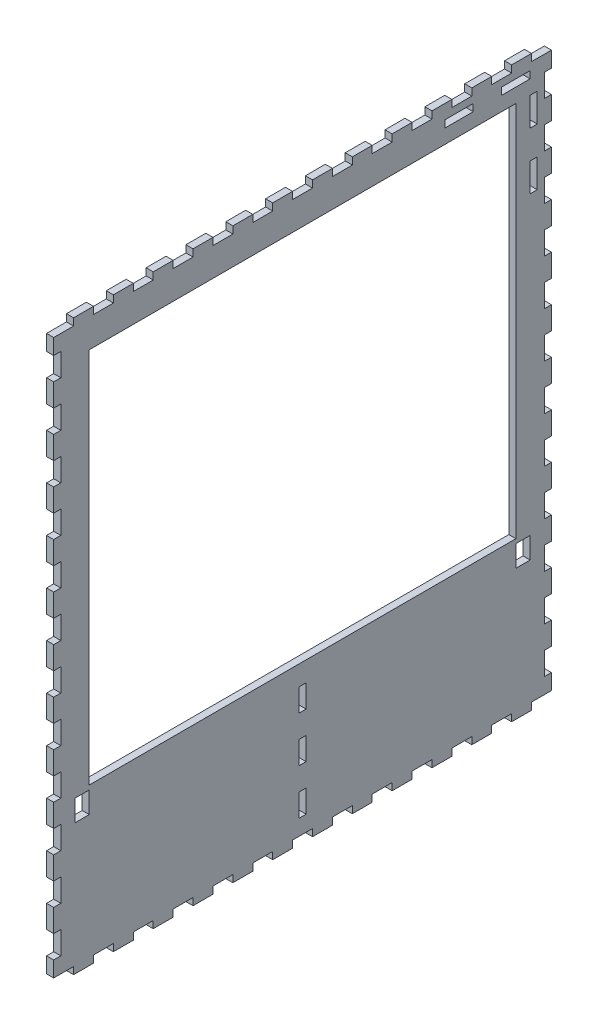
from build123d import *

# Parameters (mm, degrees)
ESQUISSE1_W                = 350
ESQUISSE1_H                = 400
BOSS_EXTRU_1_DEPTH         = 5
ESQUISSE2_W                = 14
ESQUISSE2_H                = 5
ENL_V_MAT_EXTRU_1_DEPTH    = 5
R_P_TITION_LIN_AIRE1_COUNT = 13
R_P_TITION_LIN_AIRE1_PITCH = 28
SYM_TRIE1_COPY_1_SKETCH_W  = 14
SYM_TRIE1_COPY_1_SKETCH_H  = 5
SYM_TRIE1_COPY_1_DEPTH     = 5
SYM_TRIE1_COPY_2_SKETCH_W  = 14
SYM_TRIE1_COPY_2_SKETCH_H  = 5
SYM_TRIE1_COPY_2_DEPTH     = 5
SYM_TRIE1_COPY_3_SKETCH_W  = 14
SYM_TRIE1_COPY_3_SKETCH_H  = 5
SYM_TRIE1_COPY_3_DEPTH     = 5
SYM_TRIE1_COPY_4_SKETCH_W  = 14
SYM_TRIE1_COPY_4_SKETCH_H  = 5
SYM_TRIE1_COPY_4_DEPTH     = 5
SYM_TRIE1_COPY_5_SKETCH_W  = 14
SYM_TRIE1_COPY_5_SKETCH_H  = 5
SYM_TRIE1_COPY_5_DEPTH     = 5
SYM_TRIE1_COPY_6_SKETCH_W  = 14
SYM_TRIE1_COPY_6_SKETCH_H  = 5
SYM_TRIE1_COPY_6_DEPTH     = 5
SYM_TRIE1_COPY_7_SKETCH_W  = 14
SYM_TRIE1_COPY_7_SKETCH_H  = 5
SYM_TRIE1_COPY_7_DEPTH     = 5
SYM_TRIE1_COPY_8_SKETCH_W  = 14
SYM_TRIE1_COPY_8_SKETCH_H  = 5
SYM_TRIE1_COPY_8_DEPTH     = 5
SYM_TRIE1_COPY_9_SKETCH_W  = 14
SYM_TRIE1_COPY_9_SKETCH_H  = 5
SYM_TRIE1_COPY_9_DEPTH     = 5
SYM_TRIE1_COPY_10_SKETCH_W = 14
SYM_TRIE1_COPY_10_SKETCH_H = 5
SYM_TRIE1_COPY_10_DEPTH    = 5
SYM_TRIE1_COPY_11_SKETCH_W = 14
SYM_TRIE1_COPY_11_SKETCH_H = 5
SYM_TRIE1_COPY_11_DEPTH    = 5
SYM_TRIE1_COPY_12_SKETCH_W = 14
SYM_TRIE1_COPY_12_SKETCH_H = 5
SYM_TRIE1_COPY_12_DEPTH    = 5
ESQUISSE3_W                = 5
ESQUISSE3_H                = 16
ENL_V_MAT_EXTRU_2_DEPTH    = 5
R_P_TITION_LIN_AIRE2_COUNT = 12
R_P_TITION_LIN_AIRE2_PITCH = 32
SYM_TRIE2_COPY_1_SKETCH_W  = 5
SYM_TRIE2_COPY_1_SKETCH_H  = 16
SYM_TRIE2_COPY_1_DEPTH     = 5
SYM_TRIE2_COPY_2_SKETCH_W  = 5
SYM_TRIE2_COPY_2_SKETCH_H  = 16
SYM_TRIE2_COPY_2_DEPTH     = 5
SYM_TRIE2_COPY_3_SKETCH_W  = 5
SYM_TRIE2_COPY_3_SKETCH_H  = 16
SYM_TRIE2_COPY_3_DEPTH     = 5
SYM_TRIE2_COPY_4_SKETCH_W  = 5
SYM_TRIE2_COPY_4_SKETCH_H  = 16
SYM_TRIE2_COPY_4_DEPTH     = 5
SYM_TRIE2_COPY_5_SKETCH_W  = 5
SYM_TRIE2_COPY_5_SKETCH_H  = 16
SYM_TRIE2_COPY_5_DEPTH     = 5
SYM_TRIE2_COPY_6_SKETCH_W  = 5
SYM_TRIE2_COPY_6_SKETCH_H  = 16
SYM_TRIE2_COPY_6_DEPTH     = 5
SYM_TRIE2_COPY_7_SKETCH_W  = 5
SYM_TRIE2_COPY_7_SKETCH_H  = 16
SYM_TRIE2_COPY_7_DEPTH     = 5
SYM_TRIE2_COPY_8_SKETCH_W  = 5
SYM_TRIE2_COPY_8_SKETCH_H  = 16
SYM_TRIE2_COPY_8_DEPTH     = 5
SYM_TRIE2_COPY_9_SKETCH_W  = 5
SYM_TRIE2_COPY_9_SKETCH_H  = 16
SYM_TRIE2_COPY_9_DEPTH     = 5
SYM_TRIE2_COPY_10_SKETCH_W = 5
SYM_TRIE2_COPY_10_SKETCH_H = 16
SYM_TRIE2_COPY_10_DEPTH    = 5
SYM_TRIE2_COPY_11_SKETCH_W = 5
SYM_TRIE2_COPY_11_SKETCH_H = 16
SYM_TRIE2_COPY_11_DEPTH    = 5
ESQUISSE4_W                = 300
ESQUISSE4_H                = 265
ENL_V_MAT_EXTRU_3_DEPTH    = 5
ESQUISSE5_W                = 10
ESQUISSE5_H                = 15
ENL_V_MAT_EXTRU_4_DEPTH    = 5
ESQUISSE6_W                = 5
ESQUISSE6_H                = 16
ENL_V_MAT_EXTRU_5_DEPTH    = 5
R_P_TITION_LIN_AIRE3_COUNT = 3
R_P_TITION_LIN_AIRE3_PITCH = 32
ESQUISSE7_W                = 20
ESQUISSE7_H                = 5
ESQUISSE7_W_2              = 5
ESQUISSE7_H_2              = 20
ENL_V_MAT_EXTRU_6_DEPTH    = 10


with BuildPart() as part:
    # Esquisse1 → Boss.-Extru.1 (new body)
    with BuildSketch(Plane(origin=(0, 0, 0), x_dir=(0, 0, -1), z_dir=(1, 0, 0))):
        with Locations((175, -200)):
            Rectangle(ESQUISSE1_W, ESQUISSE1_H)
    extrude(amount=BOSS_EXTRU_1_DEPTH)

    # Esquisse2 → Enlèv. mat.-Extru.1 (cut)
    with BuildSketch(Plane(origin=(5, 0, 0), x_dir=(0, 0, -1), z_dir=(1, 0, 0))):
        with Locations((343, -397.5)):
            Rectangle(ESQUISSE2_W, ESQUISSE2_H)
    enl_v_mat_extru_1 = extrude(amount=-ENL_V_MAT_EXTRU_1_DEPTH, mode=Mode.SUBTRACT)

    # Répétition linéaire1: Enlèv. mat.-Extru.1 ×13
    with Locations(*[(0, 0, i * R_P_TITION_LIN_AIRE1_PITCH) for i in range(1, R_P_TITION_LIN_AIRE1_COUNT)]):
        add(enl_v_mat_extru_1, mode=Mode.SUBTRACT)

    # Symétrie1: Enlèv. mat.-Extru.1 across plane
    add(enl_v_mat_extru_1.mirror(Plane(origin=(0, -200, 0), x_dir=(0, 0, 1), z_dir=(0, -1, 0))), mode=Mode.SUBTRACT)

    # Symétrie1 copy 1 sketch → Symétrie1 copy 1 (cut)
    with BuildSketch(Plane(origin=(5, -400, 28), x_dir=(0, 0, -1), z_dir=(1, 0, 0))):
        with Locations((343, 397.5)):
            Rectangle(SYM_TRIE1_COPY_1_SKETCH_W, SYM_TRIE1_COPY_1_SKETCH_H)
    extrude(amount=-SYM_TRIE1_COPY_1_DEPTH, mode=Mode.SUBTRACT)

    # Symétrie1 copy 2 sketch → Symétrie1 copy 2 (cut)
    with BuildSketch(Plane(origin=(5, -400, 56), x_dir=(0, 0, -1), z_dir=(1, 0, 0))):
        with Locations((343, 397.5)):
            Rectangle(SYM_TRIE1_COPY_2_SKETCH_W, SYM_TRIE1_COPY_2_SKETCH_H)
    extrude(amount=-SYM_TRIE1_COPY_2_DEPTH, mode=Mode.SUBTRACT)

    # Symétrie1 copy 3 sketch → Symétrie1 copy 3 (cut)
    with BuildSketch(Plane(origin=(5, -400, 84), x_dir=(0, 0, -1), z_dir=(1, 0, 0))):
        with Locations((343, 397.5)):
            Rectangle(SYM_TRIE1_COPY_3_SKETCH_W, SYM_TRIE1_COPY_3_SKETCH_H)
    extrude(amount=-SYM_TRIE1_COPY_3_DEPTH, mode=Mode.SUBTRACT)

    # Symétrie1 copy 4 sketch → Symétrie1 copy 4 (cut)
    with BuildSketch(Plane(origin=(5, -400, 112), x_dir=(0, 0, -1), z_dir=(1, 0, 0))):
        with Locations((343, 397.5)):
            Rectangle(SYM_TRIE1_COPY_4_SKETCH_W, SYM_TRIE1_COPY_4_SKETCH_H)
    extrude(amount=-SYM_TRIE1_COPY_4_DEPTH, mode=Mode.SUBTRACT)

    # Symétrie1 copy 5 sketch → Symétrie1 copy 5 (cut)
    with BuildSketch(Plane(origin=(5, -400, 140), x_dir=(0, 0, -1), z_dir=(1, 0, 0))):
        with Locations((343, 397.5)):
            Rectangle(SYM_TRIE1_COPY_5_SKETCH_W, SYM_TRIE1_COPY_5_SKETCH_H)
    extrude(amount=-SYM_TRIE1_COPY_5_DEPTH, mode=Mode.SUBTRACT)

    # Symétrie1 copy 6 sketch → Symétrie1 copy 6 (cut)
    with BuildSketch(Plane(origin=(5, -400, 168), x_dir=(0, 0, -1), z_dir=(1, 0, 0))):
        with Locations((343, 397.5)):
            Rectangle(SYM_TRIE1_COPY_6_SKETCH_W, SYM_TRIE1_COPY_6_SKETCH_H)
    extrude(amount=-SYM_TRIE1_COPY_6_DEPTH, mode=Mode.SUBTRACT)

    # Symétrie1 copy 7 sketch → Symétrie1 copy 7 (cut)
    with BuildSketch(Plane(origin=(5, -400, 196), x_dir=(0, 0, -1), z_dir=(1, 0, 0))):
        with Locations((343, 397.5)):
            Rectangle(SYM_TRIE1_COPY_7_SKETCH_W, SYM_TRIE1_COPY_7_SKETCH_H)
    extrude(amount=-SYM_TRIE1_COPY_7_DEPTH, mode=Mode.SUBTRACT)

    # Symétrie1 copy 8 sketch → Symétrie1 copy 8 (cut)
    with BuildSketch(Plane(origin=(5, -400, 224), x_dir=(0, 0, -1), z_dir=(1, 0, 0))):
        with Locations((343, 397.5)):
            Rectangle(SYM_TRIE1_COPY_8_SKETCH_W, SYM_TRIE1_COPY_8_SKETCH_H)
    extrude(amount=-SYM_TRIE1_COPY_8_DEPTH, mode=Mode.SUBTRACT)

    # Symétrie1 copy 9 sketch → Symétrie1 copy 9 (cut)
    with BuildSketch(Plane(origin=(5, -400, 252), x_dir=(0, 0, -1), z_dir=(1, 0, 0))):
        with Locations((343, 397.5)):
            Rectangle(SYM_TRIE1_COPY_9_SKETCH_W, SYM_TRIE1_COPY_9_SKETCH_H)
    extrude(amount=-SYM_TRIE1_COPY_9_DEPTH, mode=Mode.SUBTRACT)

    # Symétrie1 copy 10 sketch → Symétrie1 copy 10 (cut)
    with BuildSketch(Plane(origin=(5, -400, 280), x_dir=(0, 0, -1), z_dir=(1, 0, 0))):
        with Locations((343, 397.5)):
            Rectangle(SYM_TRIE1_COPY_10_SKETCH_W, SYM_TRIE1_COPY_10_SKETCH_H)
    extrude(amount=-SYM_TRIE1_COPY_10_DEPTH, mode=Mode.SUBTRACT)

    # Symétrie1 copy 11 sketch → Symétrie1 copy 11 (cut)
    with BuildSketch(Plane(origin=(5, -400, 308), x_dir=(0, 0, -1), z_dir=(1, 0, 0))):
        with Locations((343, 397.5)):
            Rectangle(SYM_TRIE1_COPY_11_SKETCH_W, SYM_TRIE1_COPY_11_SKETCH_H)
    extrude(amount=-SYM_TRIE1_COPY_11_DEPTH, mode=Mode.SUBTRACT)

    # Symétrie1 copy 12 sketch → Symétrie1 copy 12 (cut)
    with BuildSketch(Plane(origin=(5, -400, 336), x_dir=(0, 0, -1), z_dir=(1, 0, 0))):
        with Locations((343, 397.5)):
            Rectangle(SYM_TRIE1_COPY_12_SKETCH_W, SYM_TRIE1_COPY_12_SKETCH_H)
    extrude(amount=-SYM_TRIE1_COPY_12_DEPTH, mode=Mode.SUBTRACT)

    # Esquisse3 → Enlèv. mat.-Extru.2 (cut)
    with BuildSketch(Plane(origin=(5, 0, 0), x_dir=(0, 0, -1), z_dir=(1, 0, 0))):
        with Locations((347.5, -376)):
            Rectangle(ESQUISSE3_W, ESQUISSE3_H)
    enl_v_mat_extru_2 = extrude(amount=-ENL_V_MAT_EXTRU_2_DEPTH, mode=Mode.SUBTRACT)

    # Répétition linéaire2: Enlèv. mat.-Extru.2 ×12
    with Locations(*[(0, i * R_P_TITION_LIN_AIRE2_PITCH, 0) for i in range(1, R_P_TITION_LIN_AIRE2_COUNT)]):
        add(enl_v_mat_extru_2, mode=Mode.SUBTRACT)

    # Symétrie2: Enlèv. mat.-Extru.2 across plane
    add(enl_v_mat_extru_2.mirror(Plane(origin=(0, 0, -175), x_dir=(1, 0, 0), z_dir=(0, 0, -1))), mode=Mode.SUBTRACT)

    # Symétrie2 copy 1 sketch → Symétrie2 copy 1 (cut)
    with BuildSketch(Plane(origin=(5, 32, -350), x_dir=(0, 0, 1), z_dir=(1, 0, 0))):
        with Locations((347.5, 376)):
            Rectangle(SYM_TRIE2_COPY_1_SKETCH_W, SYM_TRIE2_COPY_1_SKETCH_H)
    extrude(amount=-SYM_TRIE2_COPY_1_DEPTH, mode=Mode.SUBTRACT)

    # Symétrie2 copy 2 sketch → Symétrie2 copy 2 (cut)
    with BuildSketch(Plane(origin=(5, 64, -350), x_dir=(0, 0, 1), z_dir=(1, 0, 0))):
        with Locations((347.5, 376)):
            Rectangle(SYM_TRIE2_COPY_2_SKETCH_W, SYM_TRIE2_COPY_2_SKETCH_H)
    extrude(amount=-SYM_TRIE2_COPY_2_DEPTH, mode=Mode.SUBTRACT)

    # Symétrie2 copy 3 sketch → Symétrie2 copy 3 (cut)
    with BuildSketch(Plane(origin=(5, 96, -350), x_dir=(0, 0, 1), z_dir=(1, 0, 0))):
        with Locations((347.5, 376)):
            Rectangle(SYM_TRIE2_COPY_3_SKETCH_W, SYM_TRIE2_COPY_3_SKETCH_H)
    extrude(amount=-SYM_TRIE2_COPY_3_DEPTH, mode=Mode.SUBTRACT)

    # Symétrie2 copy 4 sketch → Symétrie2 copy 4 (cut)
    with BuildSketch(Plane(origin=(5, 128, -350), x_dir=(0, 0, 1), z_dir=(1, 0, 0))):
        with Locations((347.5, 376)):
            Rectangle(SYM_TRIE2_COPY_4_SKETCH_W, SYM_TRIE2_COPY_4_SKETCH_H)
    extrude(amount=-SYM_TRIE2_COPY_4_DEPTH, mode=Mode.SUBTRACT)

    # Symétrie2 copy 5 sketch → Symétrie2 copy 5 (cut)
    with BuildSketch(Plane(origin=(5, 160, -350), x_dir=(0, 0, 1), z_dir=(1, 0, 0))):
        with Locations((347.5, 376)):
            Rectangle(SYM_TRIE2_COPY_5_SKETCH_W, SYM_TRIE2_COPY_5_SKETCH_H)
    extrude(amount=-SYM_TRIE2_COPY_5_DEPTH, mode=Mode.SUBTRACT)

    # Symétrie2 copy 6 sketch → Symétrie2 copy 6 (cut)
    with BuildSketch(Plane(origin=(5, 192, -350), x_dir=(0, 0, 1), z_dir=(1, 0, 0))):
        with Locations((347.5, 376)):
            Rectangle(SYM_TRIE2_COPY_6_SKETCH_W, SYM_TRIE2_COPY_6_SKETCH_H)
    extrude(amount=-SYM_TRIE2_COPY_6_DEPTH, mode=Mode.SUBTRACT)

    # Symétrie2 copy 7 sketch → Symétrie2 copy 7 (cut)
    with BuildSketch(Plane(origin=(5, 224, -350), x_dir=(0, 0, 1), z_dir=(1, 0, 0))):
        with Locations((347.5, 376)):
            Rectangle(SYM_TRIE2_COPY_7_SKETCH_W, SYM_TRIE2_COPY_7_SKETCH_H)
    extrude(amount=-SYM_TRIE2_COPY_7_DEPTH, mode=Mode.SUBTRACT)

    # Symétrie2 copy 8 sketch → Symétrie2 copy 8 (cut)
    with BuildSketch(Plane(origin=(5, 256, -350), x_dir=(0, 0, 1), z_dir=(1, 0, 0))):
        with Locations((347.5, 376)):
            Rectangle(SYM_TRIE2_COPY_8_SKETCH_W, SYM_TRIE2_COPY_8_SKETCH_H)
    extrude(amount=-SYM_TRIE2_COPY_8_DEPTH, mode=Mode.SUBTRACT)

    # Symétrie2 copy 9 sketch → Symétrie2 copy 9 (cut)
    with BuildSketch(Plane(origin=(5, 288, -350), x_dir=(0, 0, 1), z_dir=(1, 0, 0))):
        with Locations((347.5, 376)):
            Rectangle(SYM_TRIE2_COPY_9_SKETCH_W, SYM_TRIE2_COPY_9_SKETCH_H)
    extrude(amount=-SYM_TRIE2_COPY_9_DEPTH, mode=Mode.SUBTRACT)

    # Symétrie2 copy 10 sketch → Symétrie2 copy 10 (cut)
    with BuildSketch(Plane(origin=(5, 320, -350), x_dir=(0, 0, 1), z_dir=(1, 0, 0))):
        with Locations((347.5, 376)):
            Rectangle(SYM_TRIE2_COPY_10_SKETCH_W, SYM_TRIE2_COPY_10_SKETCH_H)
    extrude(amount=-SYM_TRIE2_COPY_10_DEPTH, mode=Mode.SUBTRACT)

    # Symétrie2 copy 11 sketch → Symétrie2 copy 11 (cut)
    with BuildSketch(Plane(origin=(5, 352, -350), x_dir=(0, 0, 1), z_dir=(1, 0, 0))):
        with Locations((347.5, 376)):
            Rectangle(SYM_TRIE2_COPY_11_SKETCH_W, SYM_TRIE2_COPY_11_SKETCH_H)
    extrude(amount=-SYM_TRIE2_COPY_11_DEPTH, mode=Mode.SUBTRACT)

    # Esquisse4 → Enlèv. mat.-Extru.3 (cut)
    with BuildSketch(Plane(origin=(5, 0, 0), x_dir=(0, 0, -1), z_dir=(1, 0, 0))):
        with Locations((175, -157.5)):
            Rectangle(ESQUISSE4_W, ESQUISSE4_H)
    extrude(amount=-ENL_V_MAT_EXTRU_3_DEPTH, mode=Mode.SUBTRACT)

    # Esquisse5 → Enlèv. mat.-Extru.4 (cut)
    with BuildSketch(Plane(origin=(5, 0, 0), x_dir=(0, 0, -1), z_dir=(1, 0, 0))):
        with Locations((330, -300.5)):
            Rectangle(ESQUISSE5_W, ESQUISSE5_H)
    enl_v_mat_extru_4 = extrude(amount=-ENL_V_MAT_EXTRU_4_DEPTH, mode=Mode.SUBTRACT)

    # Symétrie3: Enlèv. mat.-Extru.4 across plane
    add(enl_v_mat_extru_4.mirror(Plane(origin=(0, 0, -175), x_dir=(1, 0, 0), z_dir=(0, 0, -1))), mode=Mode.SUBTRACT)

    # Esquisse6 → Enlèv. mat.-Extru.5 (cut)
    with BuildSketch(Plane(origin=(5, 0, 0), x_dir=(0, 0, -1), z_dir=(1, 0, 0))):
        with Locations((175, -376)):
            Rectangle(ESQUISSE6_W, ESQUISSE6_H)
    enl_v_mat_extru_5 = extrude(amount=-ENL_V_MAT_EXTRU_5_DEPTH, mode=Mode.SUBTRACT)

    # Répétition linéaire3: Enlèv. mat.-Extru.5 ×3
    with Locations(*[(0, i * R_P_TITION_LIN_AIRE3_PITCH, 0) for i in range(1, R_P_TITION_LIN_AIRE3_COUNT)]):
        add(enl_v_mat_extru_5, mode=Mode.SUBTRACT)

    # Esquisse7 → Enlèv. mat.-Extru.6 (cut)
    with BuildSketch(Plane(origin=(5, 0, 0), x_dir=(0, 0, -1), z_dir=(1, 0, 0))):
        with Locations((285, -12.5)):
            Rectangle(ESQUISSE7_W, ESQUISSE7_H)
        with Locations((325, -12.5)):
            Rectangle(ESQUISSE7_W, ESQUISSE7_H)
        with Locations((337.5, -75)):
            Rectangle(ESQUISSE7_W_2, ESQUISSE7_H_2)
        with Locations((337.5, -35)):
            Rectangle(ESQUISSE7_W_2, ESQUISSE7_H_2)
    extrude(amount=-ENL_V_MAT_EXTRU_6_DEPTH, mode=Mode.SUBTRACT)


solid = part.part
